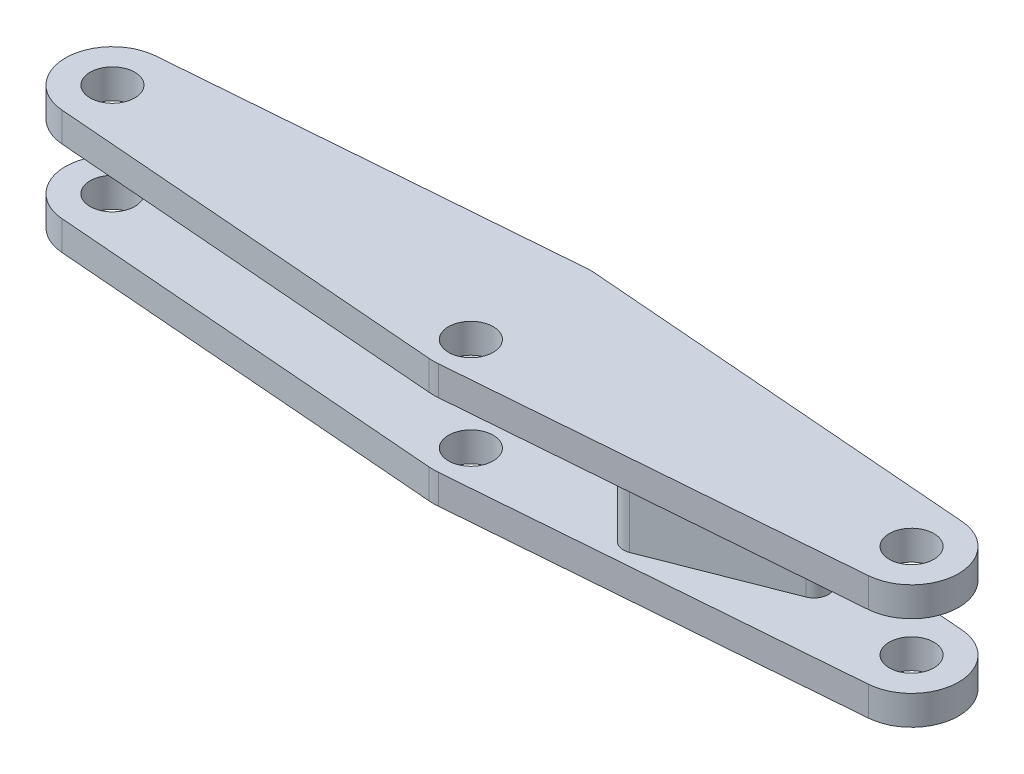
from build123d import *

# Parameters (mm, degrees)
SKETCH1_R                = 4.75
BOSS_EXTRUDE1_DEPTH      = 13.125
SKETCH2_W                = 190
SKETCH2_H                = 13.75
CUT_EXTRUDE1_DEPTH       = 34.711010303
BOSS_EXTRUDE4_DEPTH      = 6.875
BOSS_EXTRUDE4_DEPTH_BACK = 6.875


with BuildPart() as part:
    # Sketch1 → Boss-Extrude1 (new body, symmetric)
    with BuildSketch(Plane(origin=(0, 0, 0), x_dir=(1, 0, 0), z_dir=(0, 1, 0))):
        with BuildLine():
            Line((-0.984987686, 16.672141843), (-85.787990149, 9.968905232))
            ThreePointArc((-85.787990149, 9.968905232), (-95, 0), (-85.787990149, -9.968905232))
            Line((-85.787990149, -9.968905232), (-0.984987686, -16.672141843))
            ThreePointArc((-0.984987686, -16.672141843), (0, -16.711010303), (0.984987686, -16.672141843))
            Line((0.984987686, -16.672141843), (85.787990149, -9.968905232))
            ThreePointArc((85.787990149, -9.968905232), (95, 0), (85.787990149, 9.968905232))
            Line((85.787990149, 9.968905232), (0.984987686, 16.672141843))
            ThreePointArc((0.984987686, 16.672141843), (0, 16.711010303), (-0.984987686, 16.672141843))
        make_face()
        with Locations((-85, 0)):
            Circle(SKETCH1_R, mode=Mode.SUBTRACT)
        with Locations((85, 0)):
            Circle(SKETCH1_R, mode=Mode.SUBTRACT)
        with Locations((0, -8.75)):
            Circle(SKETCH1_R, mode=Mode.SUBTRACT)
    extrude(amount=BOSS_EXTRUDE1_DEPTH, both=True)

    # Sketch2 → Cut-Extrude1 (cut, through all)
    with BuildSketch(Plane.XY.offset(17)):
        Rectangle(SKETCH2_W, SKETCH2_H)
    extrude(amount=-CUT_EXTRUDE1_DEPTH, mode=Mode.SUBTRACT)

    # Sketch3 → Boss-Extrude4 (add, two sides)
    with BuildSketch(Plane(origin=(0, 0, 0), x_dir=(1, 0, 0), z_dir=(0, 1, 0))) as boss_extrude4_sk:
        with BuildLine():
            Line((33.907114097, -5.520713265), (60.914335229, 5.043850462))
            ThreePointArc((60.914335229, 5.043850462), (64.801071594, 3.342885903), (63.100107035, -0.543850462))
            Line((63.100107035, -0.543850462), (36.092885903, -11.108414189))
            ThreePointArc((36.092885903, -11.108414189), (32.206149538, -9.40744963), (33.907114097, -5.520713265))
        make_face()
    extrude(amount=BOSS_EXTRUDE4_DEPTH)
    extrude(boss_extrude4_sk.sketch, amount=-BOSS_EXTRUDE4_DEPTH_BACK)


solid = part.part
